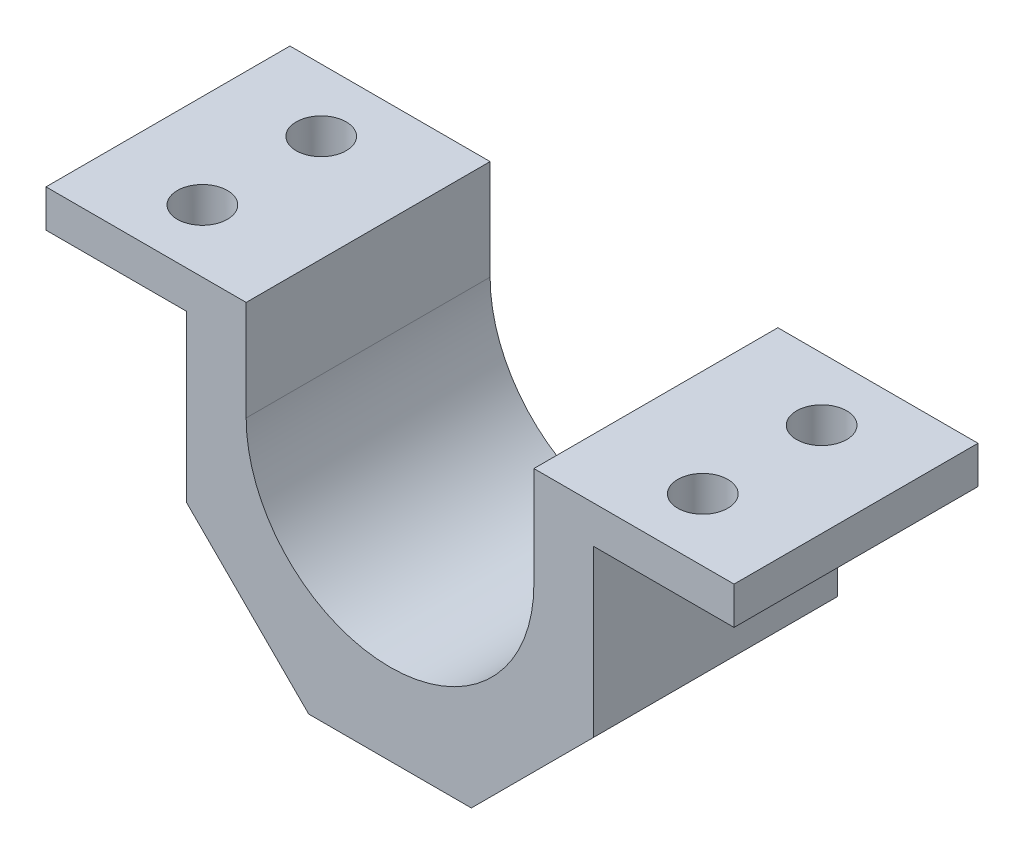
from build123d import *

# Parameters (mm, degrees)
BOSS_EXTRUDE1_DEPTH = 19.5
SKETCH2_R           = 4
CUT_EXTRUDE1_DEPTH  = 39


with BuildPart() as part:
    # Sketch1 → Boss-Extrude1 (new body, symmetric)
    with BuildSketch(Plane.XY):
        with BuildLine():
            Line((-55, 16), (-23, 16))
            Line((-23, 16), (-23, 0))
            ThreePointArc((-23, 0), (0, -23), (23, 0))
            Line((23, 0), (23, 16))
            Line((23, 16), (55, 16))
            Line((55, 16), (55, 10))
            Line((55, 10), (32.5, 10))
            Line((32.5, 10), (32.5, -16.5))
            Line((32.5, -16.5), (13, -36))
            Line((13, -36), (-13, -36))
            Line((-13, -36), (-32.5, -16.5))
            Line((-32.5, -16.5), (-32.5, 10))
            Line((-32.5, 10), (-55, 10))
            Line((-55, 10), (-55, 16))
        make_face()
    extrude(amount=BOSS_EXTRUDE1_DEPTH, both=True)

    # Sketch2 → Cut-Extrude1 (cut)
    with BuildSketch(Plane(origin=(0, 16, 0), x_dir=(1, 0, 0), z_dir=(0, 1, 0))):
        with Locations((40, 9.5)):
            Circle(SKETCH2_R)
        with Locations((40, -9.5)):
            Circle(SKETCH2_R)
        with Locations((-40, -9.5)):
            Circle(SKETCH2_R)
        with Locations((-40, 9.5)):
            Circle(SKETCH2_R)
    extrude(amount=-CUT_EXTRUDE1_DEPTH, mode=Mode.SUBTRACT)


solid = part.part
